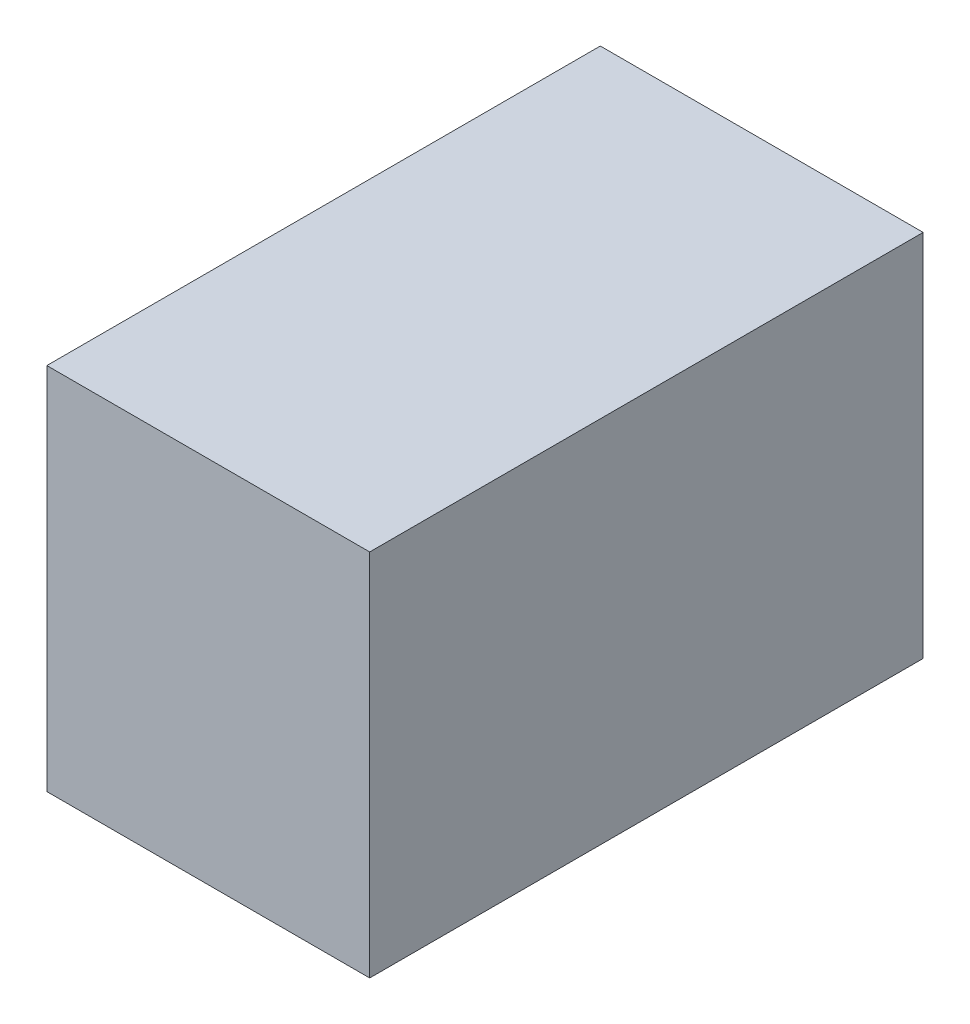
from build123d import *

# Parameters (mm, degrees)
SCHIZZO1_W                   = 35
SCHIZZO1_H                   = 40
ESTRUSIONE_ESTRUSIONE1_DEPTH = 60


with BuildPart() as part:
    # Schizzo1 → Estrusione-Estrusione1 (new body)
    with BuildSketch(Plane.XY):
        with Locations((17.5, 20)):
            Rectangle(SCHIZZO1_W, SCHIZZO1_H)
    extrude(amount=ESTRUSIONE_ESTRUSIONE1_DEPTH)


solid = part.part
